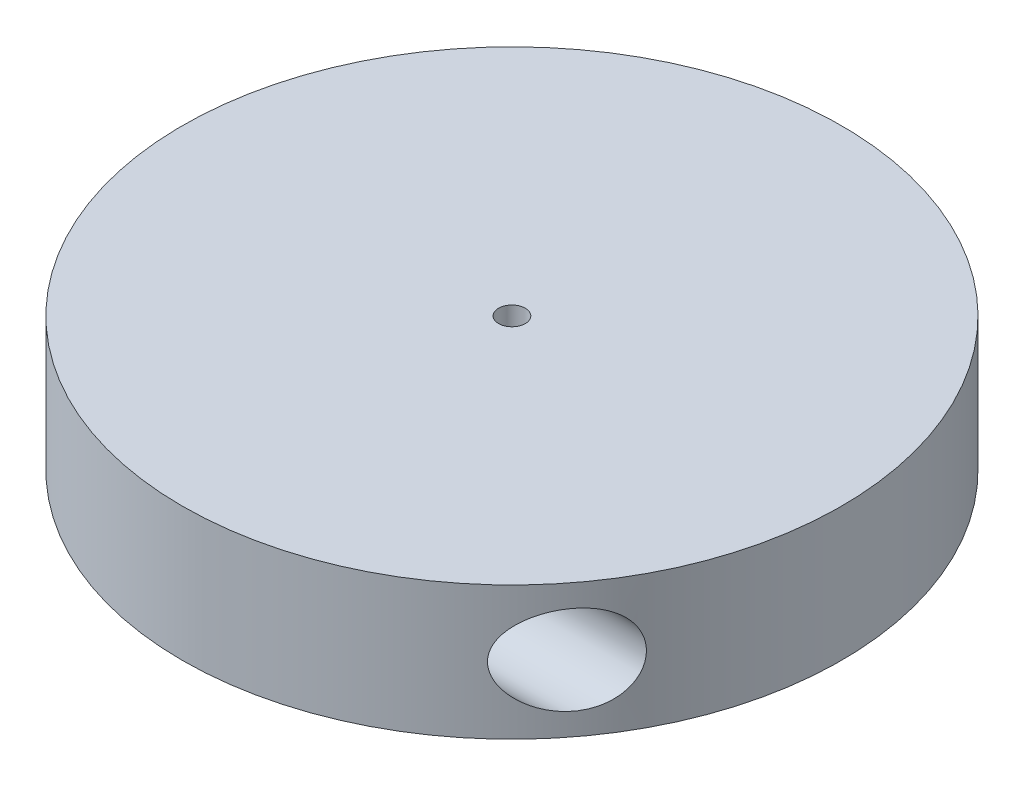
from build123d import *

# Parameters (mm, degrees)
SKETCH1_R           = 74
BOSS_EXTRUDE1_DEPTH = 30
SKETCH2_R           = 10
CUT_EXTRUDE1_DEPTH  = 80
SKETCH3_R           = 10
CUT_EXTRUDE2_DEPTH  = 80
SKETCH6_R           = 3
CUT_EXTRUDE4_DEPTH  = 30
SCALE1_SCALE        = 0.75


with BuildPart() as part:
    # Sketch1 → Boss-Extrude1 (new body)
    with BuildSketch(Plane(origin=(0, 0, 0), x_dir=(1, 0, 0), z_dir=(0, 1, 0))):
        Circle(SKETCH1_R)
    extrude(amount=BOSS_EXTRUDE1_DEPTH)

    # Sketch2 → Cut-Extrude1 (cut)
    with BuildSketch(Plane(origin=(0, 0, 0), x_dir=(0, 0, -1), z_dir=(1, 0, 0))):
        with Locations((45, 15)):
            Circle(SKETCH2_R)
    extrude(amount=-CUT_EXTRUDE1_DEPTH, mode=Mode.SUBTRACT)

    # Sketch3 → Cut-Extrude2 (cut)
    with BuildSketch(Plane(origin=(0, 0, 0), x_dir=(0, 0, -1), z_dir=(1, 0, 0))):
        with Locations((-45, 15)):
            Circle(SKETCH3_R)
    extrude(amount=CUT_EXTRUDE2_DEPTH, mode=Mode.SUBTRACT)

    # Sketch6 → Cut-Extrude4 (cut)
    with BuildSketch(Plane(origin=(0, 30, 0), x_dir=(1, 0, 0), z_dir=(0, 1, 0))):
        Circle(SKETCH6_R)
    extrude(amount=-CUT_EXTRUDE4_DEPTH, mode=Mode.SUBTRACT)


with BuildPart() as part_1:
    # Scale1: scaled about (-3.1666e-05, 14.999981435, 5.427e-06)
    add(part.part.scale(SCALE1_SCALE).moved(Location((-7.916e-06, 3.749995359, 1.357e-06))))


solid = part_1.part
